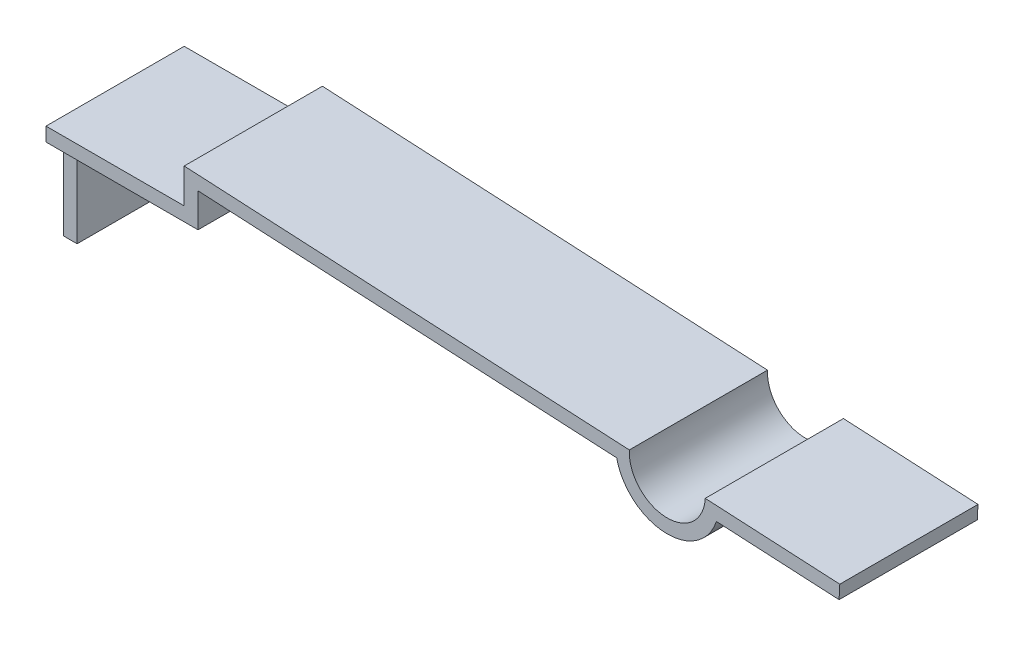
from build123d import *

# Parameters (mm, degrees)
EXTRUDE_1_DEPTH     = 2
SKETCH_3_W          = 0.25
SKETCH_3_H          = 1.3
CUT_EXTRUDE_2_DEPTH = 1.2


with BuildPart() as part:
    # 草图1 → 凸台-拉伸1 (new body)
    with BuildSketch(Plane.XY):
        with BuildLine():
            Line((0, 0), (0, 0.5))
            Line((0, 0.5), (6.441160499, 0.162433082))
            ThreePointArc((6.441160499, 0.162433082), (6.961621967, -0.415597938), (7.539652987, 0.10486353))
            Line((7.539652987, 0.10486353), (9.48698058, 0.002808416))
            Line((9.48698058, 0.002808416), (9.476513389, -0.196917491))
            Line((9.476513389, -0.196917491), (7.701790537, -0.103908208))
            ThreePointArc((7.701790537, -0.103908208), (6.951154776, -0.615323845), (6.258088567, -0.028246994))
            Line((6.258088567, -0.028246994), (0.2, 0.289243975))
            Line((0.2, 0.289243975), (0.2, -0.2))
            Line((0.2, -0.2), (-1.8, -0.2))
            Line((-1.8, -0.2), (-1.8, -1.5))
            Line((-1.8, -1.5), (-2, -1.5))
            Line((-2, -1.5), (-2, 0))
            Line((-2, 0), (0, 0))
        make_face()
    extrude(amount=EXTRUDE_1_DEPTH)

    # 草图3 → 切除-拉伸2 (cut, through all)
    with BuildSketch(Plane(origin=(-1.8, 0, 0), x_dir=(0, 0, -1), z_dir=(1, 0, 0))):
        with Locations((-1.875, -0.85)):
            Rectangle(SKETCH_3_W, SKETCH_3_H)
        with Locations((-0.125, -0.85)):
            Rectangle(SKETCH_3_W, SKETCH_3_H)
    extrude(amount=-CUT_EXTRUDE_2_DEPTH, mode=Mode.SUBTRACT)


solid = part.part
